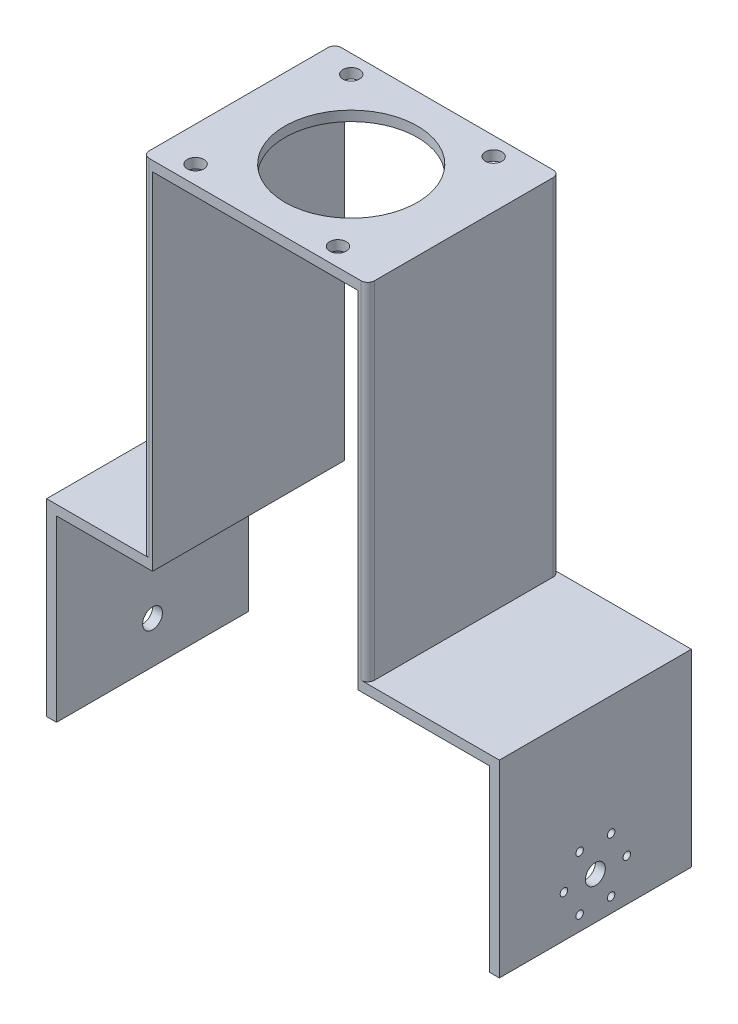
from build123d import *

# Parameters (mm, degrees)
BOSS_EXTRUDE1_DEPTH       = 58
SKETCH3_R                 = 2.5
SKETCH3_R_2               = 20
CUT_EXTRUDE1_DEPTH        = 58
SKETCH5_R                 = 3
CUT_EXTRUDE3_DEPTH        = 58
F_4_40_TAPPED_HOLE2_D     = 2.2606
F_4_40_TAPPED_HOLE2_DEPTH = 7.6
F_4_40_TAPPED_HOLE2_TIP   = 0.679152758
SKETCH15_R                = 3
CUT_EXTRUDE4_DEPTH        = 10
FILLET1_R                 = 2
FILLET2_R                 = 2
FILLET3_R                 = 2
FILLET4_R                 = 2


with BuildPart() as part:
    # Sketch2 → Boss-Extrude1 (new body)
    with BuildSketch(Plane.XY):
        Polygon((2, 51.896715462), (36, 51.896715462), (36, -52.603284538), (75.75, -52.603284538), (75.75, -109.603284538), (72.75, -109.603284538), (72.75, -55.603284538), (33, -55.603284538), (33, 48.896715462), (2, 48.896715462), (-29, 48.896715462), (-29, -55.603284538), (-58, -55.603284538), (-58, -109.603284538), (-61, -109.603284538), (-61, -52.603284538), (-32, -52.603284538), (-32, 51.896715462), align=None)
    extrude(amount=BOSS_EXTRUDE1_DEPTH)

    # Sketch3 → Cut-Extrude1 (cut)
    with BuildSketch(Plane(origin=(0, 51.896715462, 0), x_dir=(1, 0, 0), z_dir=(0, 1, 0))):
        with Locations((-21.5, -5.5)):
            Circle(SKETCH3_R)
        with Locations((21.5, -5.5)):
            Circle(SKETCH3_R)
        with Locations((21.5, -52.5)):
            Circle(SKETCH3_R)
        with Locations((-21.5, -52.5)):
            Circle(SKETCH3_R)
        with Locations((2, -29)):
            Circle(SKETCH3_R_2)
    extrude(amount=-CUT_EXTRUDE1_DEPTH, mode=Mode.SUBTRACT)

    # Sketch5 → Cut-Extrude3 (cut)
    with BuildSketch(Plane.ZY.offset(61)):
        with Locations((29, -96.903284538)):
            Circle(SKETCH5_R)
    extrude(amount=-CUT_EXTRUDE3_DEPTH, mode=Mode.SUBTRACT)

    # #4-40 Tapped Hole2
    with Locations(Plane(origin=(75.75, 0, 0), x_dir=(0, 0, -1), z_dir=(1, 0, 0))):
        with Locations((-19.5, -96.902439923), (-24.25, -105.129681259), (-33.75, -105.129681259), (-38.5, -96.902439923), (-33.75, -88.675198587), (-24.25, -88.675198587)):
            Hole(F_4_40_TAPPED_HOLE2_D / 2, depth=F_4_40_TAPPED_HOLE2_DEPTH)
            with Locations((0, 0, -(F_4_40_TAPPED_HOLE2_DEPTH + F_4_40_TAPPED_HOLE2_TIP / 2))):  # 118° drill point
                Cone(0, F_4_40_TAPPED_HOLE2_D / 2, F_4_40_TAPPED_HOLE2_TIP, mode=Mode.SUBTRACT)

    # Sketch15 → Cut-Extrude4 (cut)
    with BuildSketch(Plane(origin=(75.75, 0, 0), x_dir=(0, 0, -1), z_dir=(1, 0, 0))):
        with Locations((-29, -96.902439923)):
            Circle(SKETCH15_R)
    extrude(amount=-CUT_EXTRUDE4_DEPTH, mode=Mode.SUBTRACT)

    # Fillet1
    fillet1_edges = [part.edges().sort_by_distance(p)[0] for p in [
        (36, -0.353284538, 58),
    ]]
    fillet(fillet1_edges, radius=FILLET1_R)

    # Fillet2
    fillet2_edges = [part.edges().sort_by_distance(p)[0] for p in [
        (36, -0.353284538, 0),
    ]]
    fillet(fillet2_edges, radius=FILLET2_R)

    # Fillet3
    fillet3_edges = [part.edges().sort_by_distance(p)[0] for p in [
        (-32, -0.353284538, 0),
    ]]
    fillet(fillet3_edges, radius=FILLET3_R)

    # Fillet4
    fillet4_edges = [part.edges().sort_by_distance(p)[0] for p in [
        (-32, -0.353284538, 58),
    ]]
    fillet(fillet4_edges, radius=FILLET4_R)


solid = part.part
